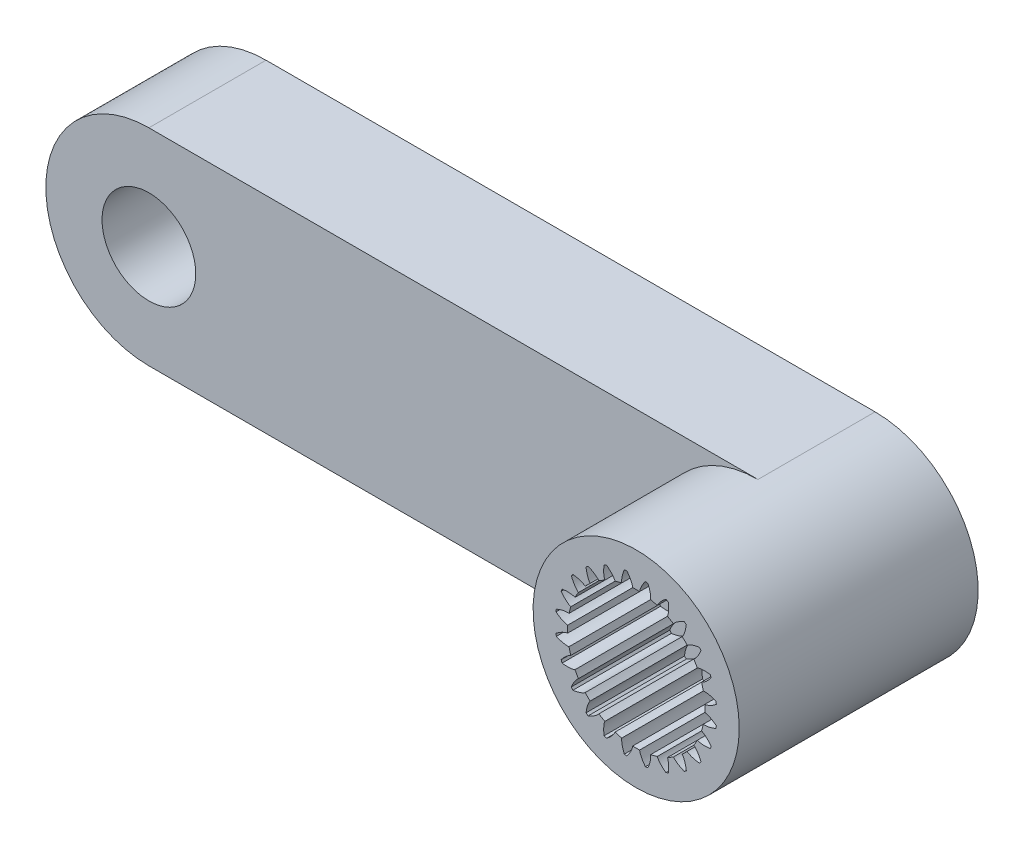
from build123d import *

# Parameters (mm, degrees)
SKETCH_1_R               = 1.979079512
SKETCH_1_R_2             = 1.7225
EXTRUDE_1_DEPTH          = 2.1
EXTRUDE_2_DEPTH          = 2.1
PATTERN_CIRCULAR_1_COUNT = 24
SKETCH_3_R               = 2.2
SKETCH_3_R_2             = 1.979079512
EXTRUDE_3_DEPTH          = 2.1
SKETCH_4_R               = 2.2
EXTRUDE_4_DEPTH          = 3
EXTRUDE_5_DEPTH          = 2.5
SKETCH_8_R               = 1
CUT_EXTRUDE_3_DEPTH      = 1
SKETCH_9_R               = 0.75
CUT_EXTRUDE_4_DEPTH      = 2
SKETCH_10_R              = 1
CUT_EXTRUDE_5_DEPTH      = 3.5


with BuildPart() as part:
    # 草图1 → 凸台-拉伸1 (new body)
    with BuildSketch(Plane.XY):
        Circle(SKETCH_1_R)
        Circle(SKETCH_1_R_2, mode=Mode.SUBTRACT)
    extrude(amount=EXTRUDE_1_DEPTH)

    # 草图2 → 凸台-拉伸2 (add)
    with BuildSketch(Plane.XY):
        with BuildLine():
            ThreePointArc((0.074064083, 1.464048288), (0, 1.465920488), (-0.074064083, 1.464048288))
            add(Edge.make_bspline(
                [(-0.074064083, 1.464048288), (-0.074342329, 1.467558404), (-0.075019525, 1.472300798), (-0.076146447, 1.478452629), (-0.077025566, 1.482761866), (-0.078118751, 1.487624879), (-0.079448745, 1.493034563), (-0.081037698, 1.498983176), (-0.082907669, 1.505462293), (-0.085080436, 1.512462829), (-0.087577536, 1.519975042), (-0.090420228, 1.527988535), (-0.093629485, 1.536492271), (-0.097225967, 1.545474573), (-0.101230012, 1.554923136), (-0.105661618, 1.564825037), (-0.110540422, 1.575166739), (-0.115885687, 1.585934104), (-0.121716286, 1.597112402), (-0.128050685, 1.608686318), (-0.134906926, 1.620639968), (-0.142302617, 1.632956905), (-0.150254907, 1.645620134), (-0.158780483, 1.658612118), (-0.167895544, 1.671914799), (-0.177615798, 1.6855096), (-0.187956432, 1.699377446), (-0.202830606, 1.718514544), (-0.214607075, 1.732748987), (-0.222766016, 1.742231037)],
                knots=[0, 0, 0, 0, 0.033052056, 0.044989685, 0.058763873, 0.074374619, 0.091821923, 0.111105785, 0.132226205, 0.155183184, 0.179976721, 0.206606817, 0.23507347, 0.265376682, 0.297516453, 0.331492781, 0.367305668, 0.404955113, 0.444441116, 0.485763678, 0.528922798, 0.573918476, 0.620750713, 0.669419507, 0.71992486, 0.772266772, 0.826445241, 0.882460269, 1, 1, 1, 1], degree=3))
            ThreePointArc((-0.222766016, 1.742231037), (0, 1.756415009), (0.222766016, 1.742231037))
            add(Edge.make_bspline(
                [(0.074064083, 1.464048288), (0.074342329, 1.467558404), (0.075019525, 1.472300798), (0.076146447, 1.478452629), (0.077025566, 1.482761866), (0.078118751, 1.487624879), (0.079448745, 1.493034563), (0.081037698, 1.498983176), (0.082907669, 1.505462293), (0.085080436, 1.512462829), (0.087577536, 1.519975042), (0.090420228, 1.527988535), (0.093629485, 1.536492271), (0.097225967, 1.545474573), (0.101230012, 1.554923136), (0.105661618, 1.564825037), (0.110540422, 1.575166739), (0.115885687, 1.585934104), (0.121716286, 1.597112402), (0.128050685, 1.608686318), (0.134906926, 1.620639968), (0.142302617, 1.632956905), (0.150254907, 1.645620134), (0.158780483, 1.658612118), (0.167895544, 1.671914799), (0.177615798, 1.6855096), (0.187956432, 1.699377446), (0.202830606, 1.718514544), (0.214607075, 1.732748987), (0.222766016, 1.742231037)],
                knots=[0, 0, 0, 0, 0.033052056, 0.044989685, 0.058763873, 0.074374619, 0.091821923, 0.111105785, 0.132226205, 0.155183184, 0.179976721, 0.206606817, 0.23507347, 0.265376682, 0.297516453, 0.331492781, 0.367305668, 0.404955113, 0.444441116, 0.485763678, 0.528922798, 0.573918476, 0.620750713, 0.669419507, 0.71992486, 0.772266772, 0.826445241, 0.882460269, 1, 1, 1, 1], degree=3))
        make_face()
    extrude_2 = extrude(amount=EXTRUDE_2_DEPTH)

    # 阵列(圆周)1: 凸台-拉伸2 ×24 about axis
    pattern_circular_1_axis = Axis((0, 0, 2.1), (0, 0, -1))
    for i in range(1, PATTERN_CIRCULAR_1_COUNT):
        add(extrude_2.rotate(pattern_circular_1_axis, i * 360 / PATTERN_CIRCULAR_1_COUNT))

    # 草图3 → 凸台-拉伸3 (add)
    with BuildSketch(Plane(origin=(0, 0, 0), x_dir=(-1, 0, 0), z_dir=(0, 0, -1))):
        Circle(SKETCH_3_R)
        Circle(SKETCH_3_R_2, mode=Mode.SUBTRACT)
    extrude(amount=-EXTRUDE_3_DEPTH)

    # 草图4 → 凸台-拉伸4 (add)
    with BuildSketch(Plane(origin=(0, 0, 0), x_dir=(-1, 0, 0), z_dir=(0, 0, -1))):
        Circle(SKETCH_4_R)
    extrude(amount=EXTRUDE_4_DEPTH)

    # 草图7 → 凸台-拉伸5 (add)
    with BuildSketch(Plane(origin=(0, 0, -3), x_dir=(-1, 0, 0), z_dir=(0, 0, -1))):
        with BuildLine():
            Line((0, 2.2), (13, 2.2))
            ThreePointArc((13, 2.2), (15.2, 0), (13, -2.2))
            Line((13, -2.2), (0, -2.2))
            ThreePointArc((0, -2.2), (-2.2, 0), (0, 2.2))
        make_face()
    extrude(amount=-EXTRUDE_5_DEPTH)

    # 草图8 → 切除-拉伸3 (cut)
    with BuildSketch(Plane.XY):
        Circle(SKETCH_8_R)
    extrude(amount=-CUT_EXTRUDE_3_DEPTH, mode=Mode.SUBTRACT)

    # 草图9 → 切除-拉伸4 (cut)
    with BuildSketch(Plane(origin=(0, 0, -3), x_dir=(-1, 0, 0), z_dir=(0, 0, -1))):
        Circle(SKETCH_9_R)
    extrude(amount=-CUT_EXTRUDE_4_DEPTH, mode=Mode.SUBTRACT)

    # 草图10 → 切除-拉伸5 (cut, through all)
    with BuildSketch(Plane.XY.offset(-0.5)):
        with Locations((-13, 0)):
            Circle(SKETCH_10_R)
    extrude(amount=-CUT_EXTRUDE_5_DEPTH, mode=Mode.SUBTRACT)


solid = part.part
